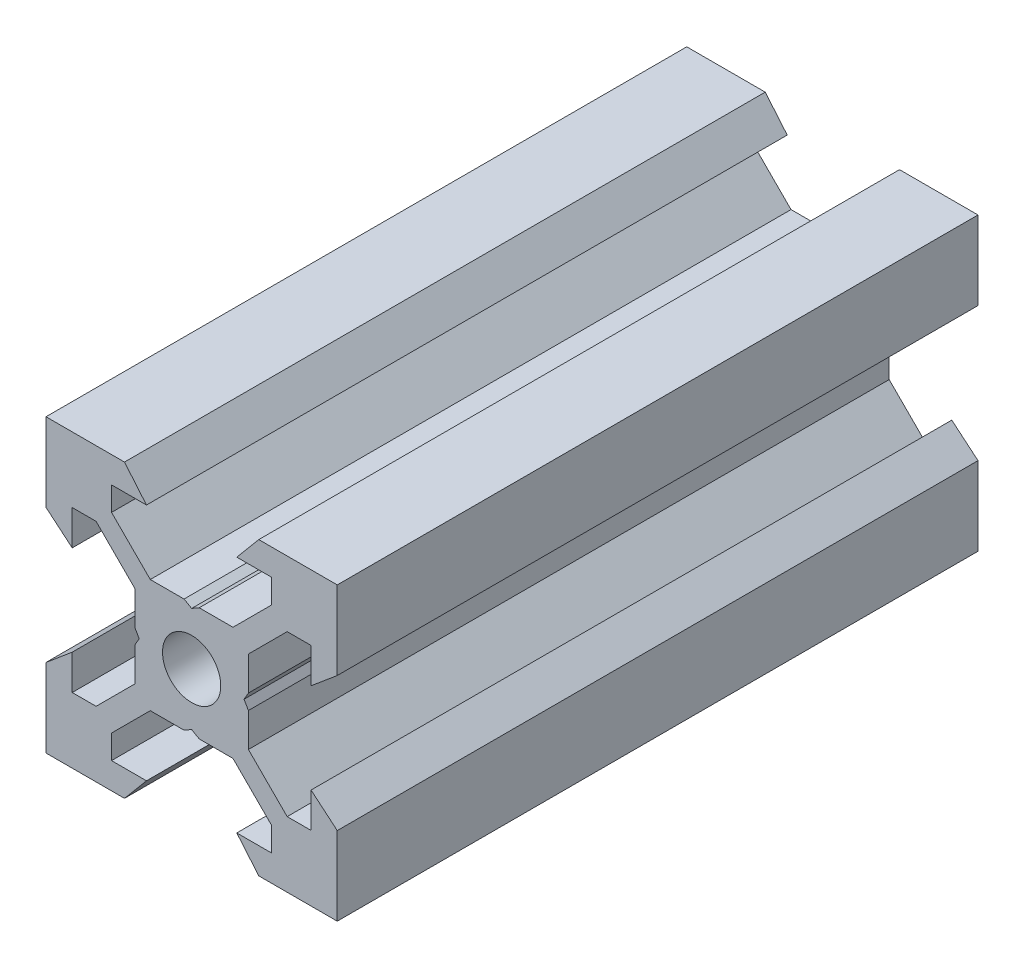
from build123d import *

# Parameters (mm, degrees)
SKETCH1_R           = 2
BOSS_EXTRUDE1_DEPTH = 22


with BuildPart() as part:
    # Sketch1 → Boss-Extrude1 (new body, symmetric)
    with BuildSketch(Plane.XY):
        Polygon((10, 10), (10, 4.610379336), (8.2, 3.1), (8.2, 5.5), (6.560660172, 5.5), (3.9, 2.839339828), (3.9, 0.519615242), (3.6, 0), (3.9, -0.519615242), (3.9, -2.839339828), (6.560660172, -5.5), (8.2, -5.5), (8.2, -3.1), (10, -4.610379336), (10, -10), (4.610379336, -10), (3.1, -8.2), (5.5, -8.2), (5.5, -6.560660172), (2.839339828, -3.9), (0.519615242, -3.9), (0, -3.6), (-0.519615242, -3.9), (-2.839339828, -3.9), (-5.5, -6.560660172), (-5.5, -8.2), (-3.1, -8.2), (-4.610379336, -10), (-10, -10), (-10, -4.610379336), (-8.2, -3.1), (-8.2, -5.5), (-6.560660172, -5.5), (-3.9, -2.839339828), (-3.9, -0.519615242), (-3.6, 0), (-3.9, 0.519615242), (-3.9, 2.839339828), (-6.560660172, 5.5), (-8.2, 5.5), (-8.2, 3.1), (-10, 4.610379336), (-10, 10), (-4.610379336, 10), (-3.1, 8.2), (-5.5, 8.2), (-5.5, 6.560660172), (-2.839339828, 3.9), (-0.519615242, 3.9), (0, 3.6), (0.519615242, 3.9), (2.839339828, 3.9), (5.5, 6.560660172), (5.5, 8.2), (3.1, 8.2), (4.610379336, 10), align=None)
        Circle(SKETCH1_R, mode=Mode.SUBTRACT)
    extrude(amount=BOSS_EXTRUDE1_DEPTH, both=True)


solid = part.part
